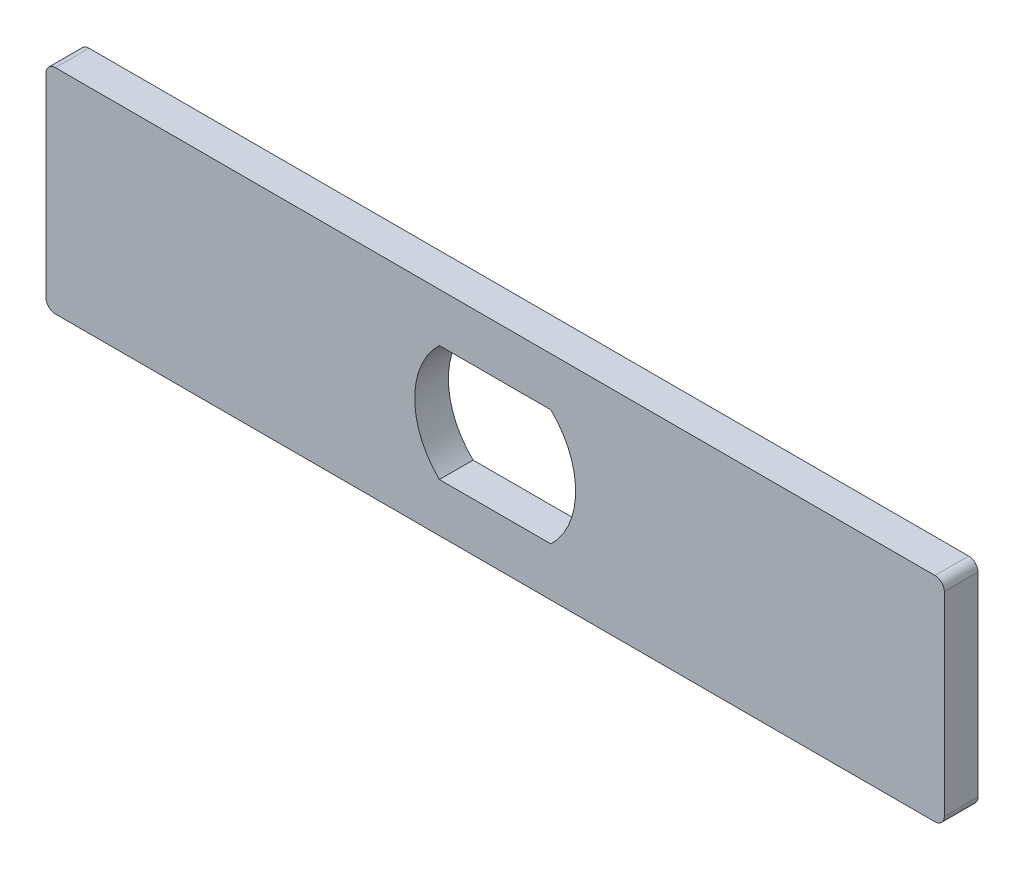
from build123d import *

# Parameters (mm, degrees)
BOSS_EXTRUDE1_DEPTH = 4.572
FILLET3_R           = 1.27
FILLET4_R           = 1.27
FILLET5_R           = 1.27
FILLET6_R           = 1.27


with BuildPart() as part:
    # Sketch1 → Boss-Extrude1 (new body)
    with BuildSketch(Plane.XY):
        Polygon((60.901141121, 14.532138101), (60.901141121, -14.423861899), (-0.058858879, -14.423861899), (-61.018858879, -14.423861899), (-61.018858879, 14.532138101), (-0.058858879, 14.532138101), align=None)
        with BuildLine():
            ThreePointArc((-7.625635449, 7.93030318), (-10.980858879, 0.054138101), (-7.625635449, -7.822026977))
            Line((-7.625635449, -7.822026977), (7.507917691, -7.822026977))
            ThreePointArc((7.507917691, -7.822026977), (10.863141121, 0.054138101), (7.507917691, 7.93030318))
            Line((7.507917691, 7.93030318), (-7.625635449, 7.93030318))
        make_face(mode=Mode.SUBTRACT)
    extrude(amount=BOSS_EXTRUDE1_DEPTH)

    # Fillet3
    fillet3_edges = [part.edges().sort_by_distance(p)[0] for p in [
        (-61.018858879, 14.532138101, 2.286),
    ]]
    fillet(fillet3_edges, radius=FILLET3_R)

    # Fillet4
    fillet4_edges = [part.edges().sort_by_distance(p)[0] for p in [
        (-61.018858879, -14.423861899, 2.286),
    ]]
    fillet(fillet4_edges, radius=FILLET4_R)

    # Fillet5
    fillet5_edges = [part.edges().sort_by_distance(p)[0] for p in [
        (60.901141121, -14.423861899, 2.286),
    ]]
    fillet(fillet5_edges, radius=FILLET5_R)

    # Fillet6
    fillet6_edges = [part.edges().sort_by_distance(p)[0] for p in [
        (60.901141121, 14.532138101, 2.286),
    ]]
    fillet(fillet6_edges, radius=FILLET6_R)


solid = part.part
